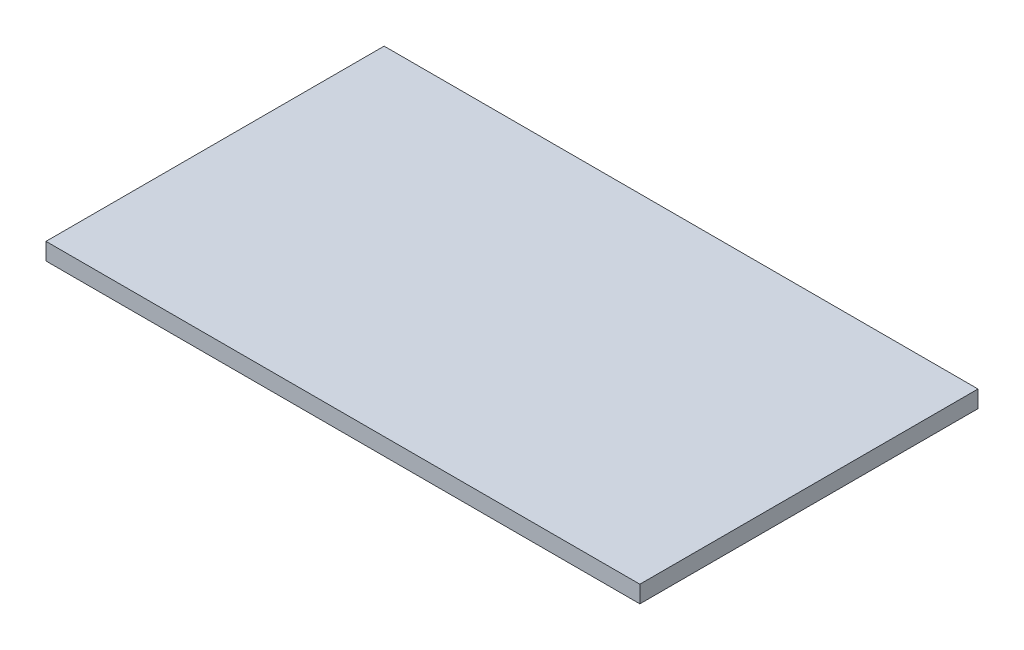
from build123d import *

# Parameters (mm, degrees)
SKETCH_1_W      = 627
SKETCH_1_H      = 357
EXTRUDE_1_DEPTH = 18


with BuildPart() as part:
    # Эскиз1 → Бобышка-Вытянуть1 (new body)
    with BuildSketch(Plane(origin=(0, 0, 0), x_dir=(1, 0, 0), z_dir=(0, 1, 0))):
        Rectangle(SKETCH_1_W, SKETCH_1_H)
    extrude(amount=EXTRUDE_1_DEPTH)


solid = part.part
